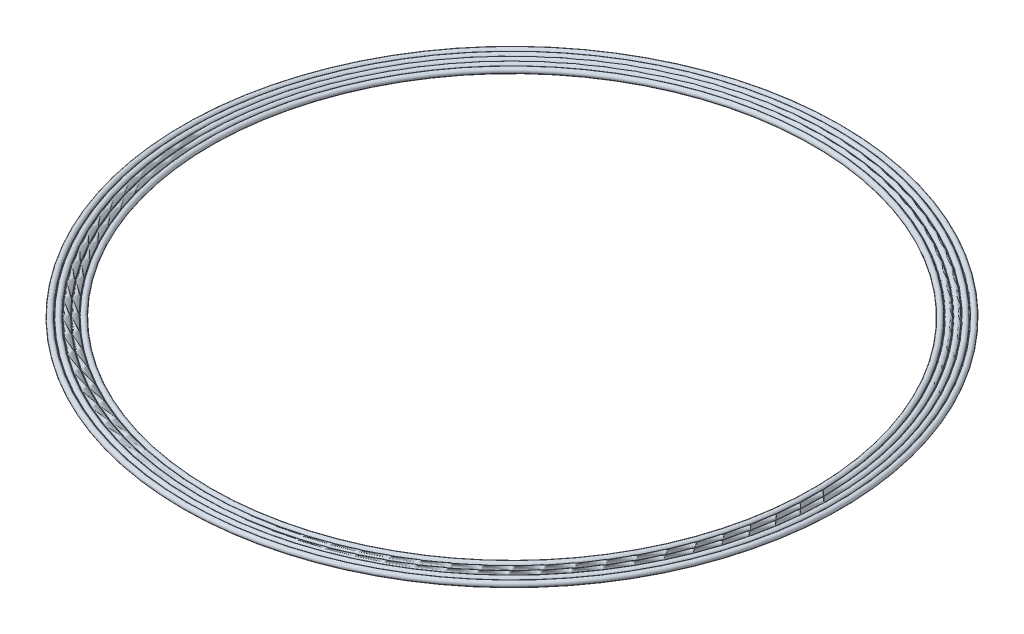
from build123d import *


with BuildPart() as part:
    # Sketch2 → Revolve1 (revolve)
    with BuildSketch(Plane.XY):
        with BuildLine():
            Line((94.326135582, 0.2), (94.523864418, 0.2))
            ThreePointArc((94.523864418, 0.2), (95.35, 0.85), (96.176135582, 0.2))
            Line((96.176135582, 0.2), (96.373864418, 0.2))
            ThreePointArc((96.373864418, 0.2), (97.2, 0.85), (98.026135582, 0.2))
            Line((98.026135582, 0.2), (98.223864418, 0.2))
            ThreePointArc((98.223864418, 0.2), (99.05, 0.85), (99.876135582, 0.2))
            Line((99.876135582, 0.2), (100.073864418, 0.2))
            ThreePointArc((100.073864418, 0.2), (101.75, 0), (100.073864418, -0.2))
            Line((100.073864418, -0.2), (99.876135582, -0.2))
            ThreePointArc((99.876135582, -0.2), (99.05, -0.85), (98.223864418, -0.2))
            Line((98.223864418, -0.2), (98.026135582, -0.2))
            ThreePointArc((98.026135582, -0.2), (97.2, -0.85), (96.373864418, -0.2))
            Line((96.373864418, -0.2), (96.176135582, -0.2))
            ThreePointArc((96.176135582, -0.2), (95.35, -0.85), (94.523864418, -0.2))
            Line((94.523864418, -0.2), (94.326135582, -0.2))
            ThreePointArc((94.326135582, -0.2), (92.65, 0), (94.326135582, 0.2))
        make_face()
    revolve(axis=Axis((0, 6.450627053, 0), (0, -1, 0)))


solid = part.part
